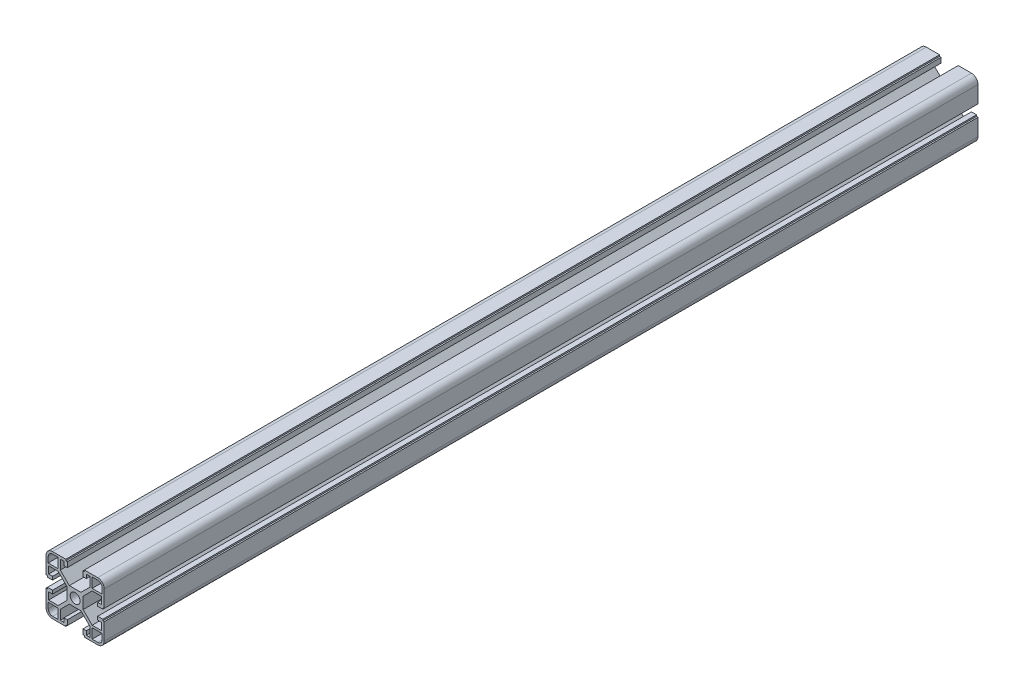
from build123d import *

# Parameters (mm, degrees)
BOSS_EXTRUDE1_DEPTH  = 600
MIRROR3_COPY_1_DEPTH = 600
MIRROR3_COPY_2_DEPTH = 600


with BuildPart() as part:
    # Sketch1 → Boss-Extrude1 (new body)
    with BuildSketch(Plane.XY):
        with BuildLine():
            Line((3.4, 0), (5.5, 0))
            Line((5.5, 0), (5.5, 4))
            Line((5.5, 4), (11.69, 10.19))
            Line((11.69, 10.19), (18.2, 10.19))
            Line((18.2, 10.19), (18.2, 5.265595036))
            Line((18.2, 5.265595036), (15.5, 5.265595036))
            Line((15.5, 5.265595036), (15.5, 2.965595036))
            Line((15.5, 2.965595036), (19, 2.965595036))
            Line((19, 2.965595036), (19, 3.965595036))
            Line((19, 3.965595036), (20, 3.965595036))
            Line((20, 3.965595036), (20, 15.5))
            ThreePointArc((20, 15.5), (18.681980515, 18.681980515), (15.5, 20))
            Line((15.5, 20), (6.385304712, 20))
            Line((6.385304712, 20), (6.385304712, 19))
            Line((6.385304712, 19), (5.385304712, 19))
            Line((5.385304712, 19), (5.385304712, 15.5))
            Line((5.385304712, 15.5), (7.685304712, 15.5))
            Line((7.685304712, 15.5), (7.685304712, 18.2))
            Line((7.685304712, 18.2), (10.19, 18.2))
            Line((10.19, 18.2), (10.19, 11.69))
            Line((10.19, 11.69), (4, 5.5))
            Line((4, 5.5), (0, 5.5))
            Line((0, 5.5), (0, 3.4))
            ThreePointArc((0, 3.4), (2.404163056, 2.404163056), (3.4, 0))
        make_face()
        with BuildLine():
            Line((18.5, 11.69), (18.5, 15.5))
            ThreePointArc((18.5, 15.5), (17.621320344, 17.621320344), (15.5, 18.5))
            Line((15.5, 18.5), (11.69, 18.5))
            Line((11.69, 18.5), (11.69, 11.69))
            Line((11.69, 11.69), (18.5, 11.69))
        make_face(mode=Mode.SUBTRACT)
    boss_extrude1 = extrude(amount=BOSS_EXTRUDE1_DEPTH)

    # Mirror1: Boss-Extrude1 across plane
    add(boss_extrude1.mirror(Plane.ZX))

    # Mirror2: Boss-Extrude1 across plane
    add(boss_extrude1.mirror(Plane(origin=(0, 0, 0), x_dir=(0, 0, 1), z_dir=(1, 0, 0))))

    # Mirror3 copy 1 sketch → Mirror3 copy 1 (add)
    with BuildSketch(Plane(origin=(0, 0, 0), x_dir=(-1, 0, 0), z_dir=(0, 0, 1))):
        with BuildLine():
            Line((3.4, 0), (5.5, 0))
            Line((5.5, 0), (5.5, 4))
            Line((5.5, 4), (11.69, 10.19))
            Line((11.69, 10.19), (18.2, 10.19))
            Line((18.2, 10.19), (18.2, 5.265595036))
            Line((18.2, 5.265595036), (15.5, 5.265595036))
            Line((15.5, 5.265595036), (15.5, 2.965595036))
            Line((15.5, 2.965595036), (19, 2.965595036))
            Line((19, 2.965595036), (19, 3.965595036))
            Line((19, 3.965595036), (20, 3.965595036))
            Line((20, 3.965595036), (20, 15.5))
            ThreePointArc((20, 15.5), (18.681980515, 18.681980515), (15.5, 20))
            Line((15.5, 20), (6.385304712, 20))
            Line((6.385304712, 20), (6.385304712, 19))
            Line((6.385304712, 19), (5.385304712, 19))
            Line((5.385304712, 19), (5.385304712, 15.5))
            Line((5.385304712, 15.5), (7.685304712, 15.5))
            Line((7.685304712, 15.5), (7.685304712, 18.2))
            Line((7.685304712, 18.2), (10.19, 18.2))
            Line((10.19, 18.2), (10.19, 11.69))
            Line((10.19, 11.69), (4, 5.5))
            Line((4, 5.5), (0, 5.5))
            Line((0, 5.5), (0, 3.4))
            ThreePointArc((0, 3.4), (2.404163056, 2.404163056), (3.4, 0))
        make_face()
        with BuildLine():
            Line((18.5, 11.69), (18.5, 15.5))
            ThreePointArc((18.5, 15.5), (17.621320344, 17.621320344), (15.5, 18.5))
            Line((15.5, 18.5), (11.69, 18.5))
            Line((11.69, 18.5), (11.69, 11.69))
            Line((11.69, 11.69), (18.5, 11.69))
        make_face(mode=Mode.SUBTRACT)
    extrude(amount=MIRROR3_COPY_1_DEPTH)

    # Mirror3 copy 2 sketch → Mirror3 copy 2 (add)
    with BuildSketch(Plane.XY):
        with BuildLine():
            Line((3.4, 0), (5.5, 0))
            Line((5.5, 0), (5.5, -4))
            Line((5.5, -4), (11.69, -10.19))
            Line((11.69, -10.19), (18.2, -10.19))
            Line((18.2, -10.19), (18.2, -5.265595036))
            Line((18.2, -5.265595036), (15.5, -5.265595036))
            Line((15.5, -5.265595036), (15.5, -2.965595036))
            Line((15.5, -2.965595036), (19, -2.965595036))
            Line((19, -2.965595036), (19, -3.965595036))
            Line((19, -3.965595036), (20, -3.965595036))
            Line((20, -3.965595036), (20, -15.5))
            ThreePointArc((20, -15.5), (18.681980515, -18.681980515), (15.5, -20))
            Line((15.5, -20), (6.385304712, -20))
            Line((6.385304712, -20), (6.385304712, -19))
            Line((6.385304712, -19), (5.385304712, -19))
            Line((5.385304712, -19), (5.385304712, -15.5))
            Line((5.385304712, -15.5), (7.685304712, -15.5))
            Line((7.685304712, -15.5), (7.685304712, -18.2))
            Line((7.685304712, -18.2), (10.19, -18.2))
            Line((10.19, -18.2), (10.19, -11.69))
            Line((10.19, -11.69), (4, -5.5))
            Line((4, -5.5), (0, -5.5))
            Line((0, -5.5), (0, -3.4))
            ThreePointArc((0, -3.4), (2.404163056, -2.404163056), (3.4, 0))
        make_face()
        with BuildLine():
            Line((18.5, -11.69), (18.5, -15.5))
            ThreePointArc((18.5, -15.5), (17.621320344, -17.621320344), (15.5, -18.5))
            Line((15.5, -18.5), (11.69, -18.5))
            Line((11.69, -18.5), (11.69, -11.69))
            Line((11.69, -11.69), (18.5, -11.69))
        make_face(mode=Mode.SUBTRACT)
    extrude(amount=MIRROR3_COPY_2_DEPTH)


solid = part.part
